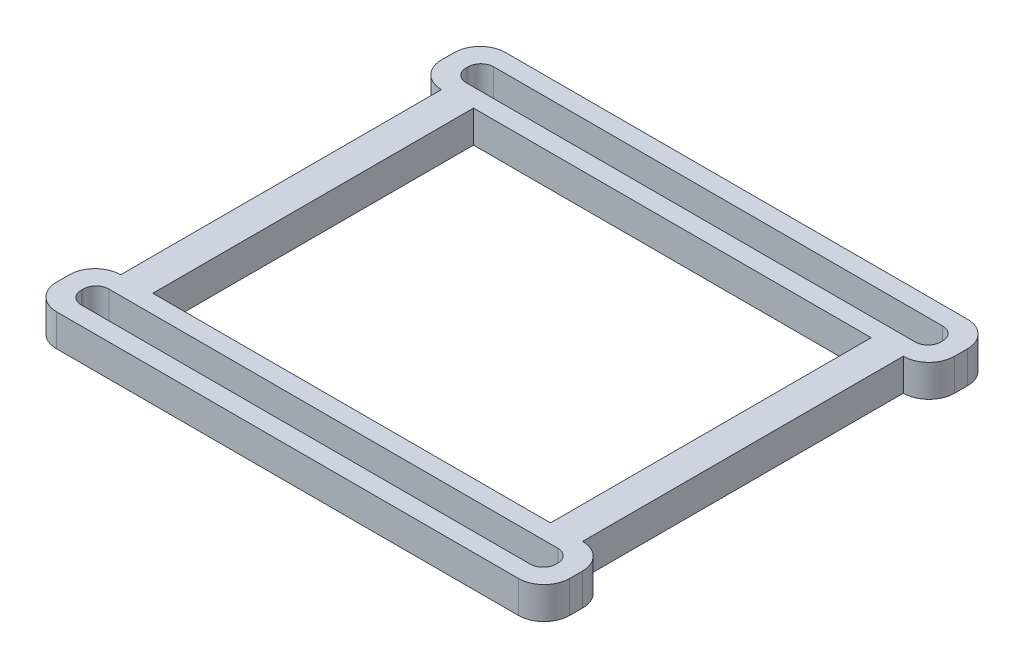
from build123d import *

# Parameters (mm, degrees)
SKETCH1_W            = 80
SKETCH1_H            = 10
BOSS_EXTRUDE1_DEPTH  = 5
SKETCH2_W            = 74
SKETCH2_H            = 4.3
CUT_EXTRUDE1_DEPTH   = 5
FILLET1_R            = 4
FILLET2_R            = 2
SKETCH3_W            = 5
SKETCH3_H            = 5
BOSS_EXTRUDE2_DEPTH  = 50
FILLET1_OF_MIRROR1_R = 4
FILLET2_OF_MIRROR1_R = 2


with BuildPart() as part:
    # Sketch1 → Boss-Extrude1 (new body)
    with BuildSketch(Plane(origin=(0, 0, 0), x_dir=(1, 0, 0), z_dir=(0, 1, 0))):
        Rectangle(SKETCH1_W, SKETCH1_H)
    boss_extrude1 = extrude(amount=BOSS_EXTRUDE1_DEPTH)

    # Sketch2 → Cut-Extrude1 (cut)
    with BuildSketch(Plane(origin=(0, 5, 0), x_dir=(1, 0, 0), z_dir=(0, 1, 0))):
        Rectangle(SKETCH2_W, SKETCH2_H)
    cut_extrude1 = extrude(amount=-CUT_EXTRUDE1_DEPTH, mode=Mode.SUBTRACT)

    # Fillet1
    fillet1_edges = [part.edges().sort_by_distance(p)[0] for p in [
        (40, 2.5, 5),
        (-40, 2.5, 5),
        (-40, 2.5, -5),
        (40, 2.5, -5),
    ]]
    fillet(fillet1_edges, radius=FILLET1_R)

    # Fillet2
    fillet2_edges = [part.edges().sort_by_distance(p)[0] for p in [
        (37, 2.5, -2.15),
        (37, 2.5, 2.15),
        (-37, 2.5, 2.15),
        (-37, 2.5, -2.15),
    ]]
    fillet(fillet2_edges, radius=FILLET2_R)

    # Sketch3 → Boss-Extrude2 (add)
    with BuildSketch(Plane(origin=(0, 0, -5), x_dir=(-1, 0, 0), z_dir=(0, 0, -1))):
        with Locations((-33.5, 2.5)):
            Rectangle(SKETCH3_W, SKETCH3_H)
        with Locations((33.5, 2.5)):
            Rectangle(SKETCH3_W, SKETCH3_H)
    extrude(amount=BOSS_EXTRUDE2_DEPTH)


with BuildPart() as mirror1_1:
    # Mirror1: Boss-Extrude1 across plane
    add(boss_extrude1.mirror(Plane(origin=(0, 0, -30), x_dir=(1, 0, 0), z_dir=(0, 0, -1))))

    # Mirror1 2: Cut-Extrude1 across plane
    add(cut_extrude1.mirror(Plane(origin=(0, 0, -30), x_dir=(1, 0, 0), z_dir=(0, 0, -1))), mode=Mode.SUBTRACT)

    # Fillet1 of Mirror1
    fillet1_of_mirror1_edges = [mirror1_1.edges().sort_by_distance(p)[0] for p in [
        (40, 2.5, -65),
        (-40, 2.5, -65),
        (-40, 2.5, -55),
        (40, 2.5, -55),
    ]]
    fillet(fillet1_of_mirror1_edges, radius=FILLET1_OF_MIRROR1_R)

    # Fillet2 of Mirror1
    fillet2_of_mirror1_edges = [mirror1_1.edges().sort_by_distance(p)[0] for p in [
        (37, 2.5, -57.85),
        (37, 2.5, -62.15),
        (-37, 2.5, -62.15),
        (-37, 2.5, -57.85),
    ]]
    fillet(fillet2_of_mirror1_edges, radius=FILLET2_OF_MIRROR1_R)


with BuildPart() as part_1:
    add(part.part)

    # Mirror1 united with what the copies touc: union Mirror1_1
    add(mirror1_1.part)


solid = part_1.part
